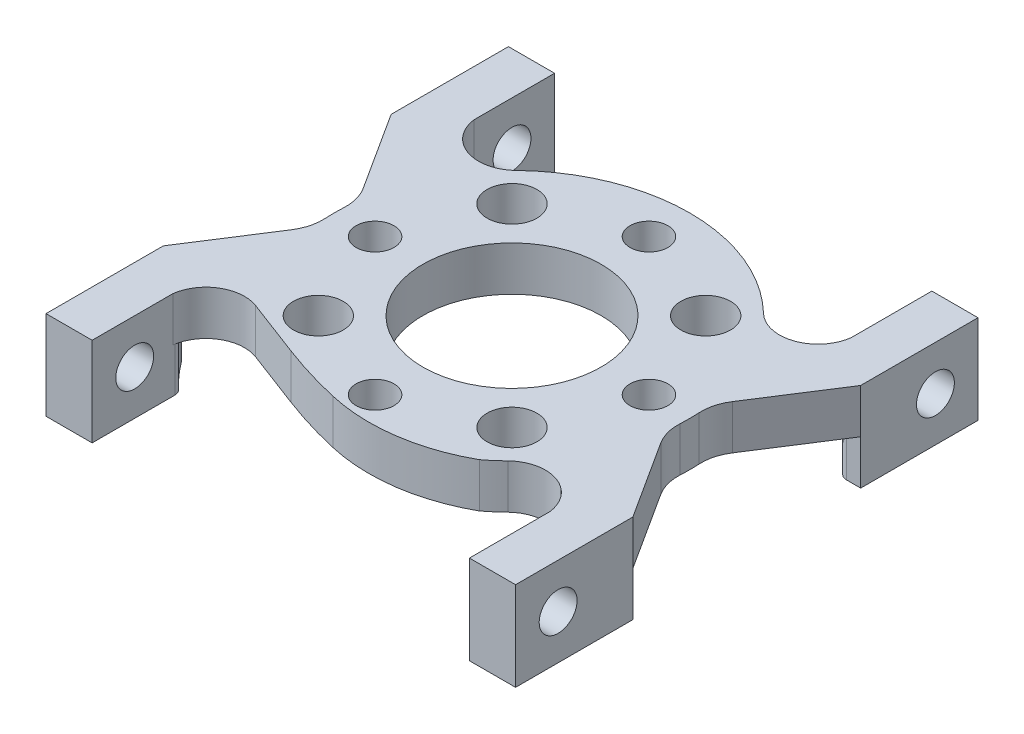
from build123d import *

# Parameters (mm, degrees)
SKETCH1_W                  = 33.528
SKETCH1_H                  = 33.02
BOSS_EXTRUDE1_DEPTH        = 3.175
CUT_EXTRUDE1_DEPTH         = 4.175
SKETCH3_W                  = 3.29438
SKETCH3_H                  = 8.37692
BOSS_EXTRUDE2_DEPTH        = 3.175
CUT_EXTRUDE2_DEPTH         = 7.35
SKETCH5_W                  = 3.29438
SKETCH5_H                  = 8.37692
BOSS_EXTRUDE3_DEPTH        = 3.175
CUT_EXTRUDE3_DEPTH         = 7.35
SKETCH7_W                  = 3.29438
SKETCH7_H                  = 8.37692
BOSS_EXTRUDE4_DEPTH        = 3.175
CUT_EXTRUDE4_DEPTH         = 7.35
SKETCH9_W                  = 3.29438
SKETCH9_H                  = 8.37692
BOSS_EXTRUDE5_DEPTH        = 3.175
CUT_EXTRUDE5_DEPTH         = 3.175
CUT_EXTRUDE6_DEPTH         = 3.175
CUT_EXTRUDE7_DEPTH         = 3.175
CUT_EXTRUDE8_DEPTH         = 3.175
HOLE1_D                    = 12.7254
HOLE1_DEPTH                = 3.175025
M2_5_CLEARANCE_HOLE1_D     = 2.7051
M2_5_CLEARANCE_HOLE1_DEPTH = 3.175025
M3_CLEARANCE_HOLE1_D       = 3.556
M3_CLEARANCE_HOLE1_DEPTH   = 3.175025
M2_5_CLEARANCE_HOLE2_D     = 2.7051
M2_5_CLEARANCE_HOLE2_DEPTH = 3.29438
M2_5_CLEARANCE_HOLE3_D     = 2.7051
M2_5_CLEARANCE_HOLE3_DEPTH = 3.29438
M2_5_CLEARANCE_HOLE4_D     = 2.7051
M2_5_CLEARANCE_HOLE4_DEPTH = 3.29443
FILLET1_R                  = 0.635
FILLET2_R                  = 3.175
CUT_EXTRUDE9_REACH         = 5.175
CUT_EXTRUDE12_REACH        = 7.42
SKETCH30_W                 = 14.449204344
SKETCH30_H                 = 9.791237154


with BuildPart() as part:
    # Sketch1 → Boss-Extrude1 (new body)
    with BuildSketch(Plane.XZ):
        Rectangle(SKETCH1_W, SKETCH1_H)
    extrude(amount=-BOSS_EXTRUDE1_DEPTH)

    # Sketch2 → Cut-Extrude1 (cut, through all)
    with BuildSketch(Plane(origin=(0, 3.175, 0), x_dir=(-1, 0, 0), z_dir=(0, 1, 0))):
        with BuildLine():
            Line((-13.46962, 16.51), (-13.46962, 10.753335779))
            ThreePointArc((-13.46962, 10.753335779), (-11.652039651, 8.508623021), (-8.8307675, 9.127296717))
            ThreePointArc((-8.8307675, 9.127296717), (0, 12.7), (8.8307675, 9.127296717))
            ThreePointArc((8.8307675, 9.127296717), (11.652039651, 8.508623021), (13.46962, 10.753335779))
            Line((13.46962, 10.753335779), (13.46962, 16.51))
            Line((13.46962, 16.51), (-13.46962, 16.51))
        make_face()
    extrude(amount=-CUT_EXTRUDE1_DEPTH, mode=Mode.SUBTRACT)

    # Sketch3 → Boss-Extrude2 (add)
    with BuildSketch(Plane.XZ):
        with Locations((-15.11681, 12.32154)):
            Rectangle(SKETCH3_W, SKETCH3_H)
    extrude(amount=BOSS_EXTRUDE2_DEPTH)

    # Sketch4 → Cut-Extrude2 (cut, through all)
    with BuildSketch(Plane(origin=(0, 3.175, 0), x_dir=(-1, 0, 0), z_dir=(0, 1, 0))):
        with BuildLine():
            Line((-16.764, 8.13308), (-16.764, -8.13308))
            Line((-16.764, -8.13308), (-12.593680427, -1.639882101))
            ThreePointArc((-12.593680427, -1.639882101), (-12.7, 0), (-12.593680427, 1.639882101))
            Line((-12.593680427, 1.639882101), (-16.764, 8.13308))
        make_face()
    extrude(amount=-CUT_EXTRUDE2_DEPTH, mode=Mode.SUBTRACT)

    # Sketch5 → Boss-Extrude3 (add)
    with BuildSketch(Plane.XZ):
        with Locations((15.11681, 12.32154)):
            Rectangle(SKETCH5_W, SKETCH5_H)
    extrude(amount=BOSS_EXTRUDE3_DEPTH)

    # Sketch6 → Cut-Extrude3 (cut, through all)
    with BuildSketch(Plane(origin=(0, 3.175, 0), x_dir=(-1, 0, 0), z_dir=(0, 1, 0))):
        with BuildLine():
            Line((13.46962, -16.51), (13.46962, -10.753335779))
            ThreePointArc((13.46962, -10.753335779), (11.652039651, -8.508623021), (8.8307675, -9.127296717))
            ThreePointArc((8.8307675, -9.127296717), (0, -12.7), (-8.8307675, -9.127296717))
            ThreePointArc((-8.8307675, -9.127296717), (-11.652039651, -8.508623021), (-13.46962, -10.753335779))
            Line((-13.46962, -10.753335779), (-13.46962, -16.51))
            Line((-13.46962, -16.51), (13.46962, -16.51))
        make_face()
    extrude(amount=-CUT_EXTRUDE3_DEPTH, mode=Mode.SUBTRACT)

    # Sketch7 → Boss-Extrude4 (add)
    with BuildSketch(Plane.XZ):
        with Locations((15.11681, -12.32154)):
            Rectangle(SKETCH7_W, SKETCH7_H)
    extrude(amount=BOSS_EXTRUDE4_DEPTH)

    # Sketch8 → Cut-Extrude4 (cut, through all)
    with BuildSketch(Plane(origin=(0, 3.175, 0), x_dir=(-1, 0, 0), z_dir=(0, 1, 0))):
        with BuildLine():
            Line((16.764, -8.13308), (16.764, 8.13308))
            Line((16.764, 8.13308), (12.593680427, 1.639882101))
            ThreePointArc((12.593680427, 1.639882101), (12.7, 0), (12.593680427, -1.639882101))
            Line((12.593680427, -1.639882101), (16.764, -8.13308))
        make_face()
    extrude(amount=-CUT_EXTRUDE4_DEPTH, mode=Mode.SUBTRACT)

    # Sketch9 → Boss-Extrude5 (add)
    with BuildSketch(Plane.XZ):
        with Locations((-15.11681, -12.32154)):
            Rectangle(SKETCH9_W, SKETCH9_H)
    extrude(amount=BOSS_EXTRUDE5_DEPTH)

    # Sketch10 → Cut-Extrude5 (cut)
    with BuildSketch(Plane.XZ.offset(3.175)):
        with BuildLine():
            Line((15.422429016, -8.13308), (13.46962, -8.13308))
            Line((13.46962, -8.13308), (13.46962, -10.329337463))
            ThreePointArc((13.46962, -10.329337463), (14.503938678, -9.282703292), (15.422429016, -8.13308))
        make_face()
    extrude(amount=-CUT_EXTRUDE5_DEPTH, mode=Mode.SUBTRACT)

    # Sketch11 → Cut-Extrude6 (cut)
    with BuildSketch(Plane.XZ.offset(3.175)):
        with BuildLine():
            Line((13.46962, 10.329337463), (13.46962, 8.13308))
            Line((13.46962, 8.13308), (15.422429016, 8.13308))
            ThreePointArc((15.422429016, 8.13308), (14.503938678, 9.282703292), (13.46962, 10.329337463))
        make_face()
    extrude(amount=-CUT_EXTRUDE6_DEPTH, mode=Mode.SUBTRACT)

    # Sketch12 → Cut-Extrude7 (cut)
    with BuildSketch(Plane.XZ.offset(3.175)):
        with BuildLine():
            Line((-15.422429016, 8.13308), (-13.46962, 8.13308))
            Line((-13.46962, 8.13308), (-13.46962, 10.329337463))
            ThreePointArc((-13.46962, 10.329337463), (-14.503938678, 9.282703292), (-15.422429016, 8.13308))
        make_face()
    extrude(amount=-CUT_EXTRUDE7_DEPTH, mode=Mode.SUBTRACT)

    # Sketch13 → Cut-Extrude8 (cut)
    with BuildSketch(Plane.XZ.offset(3.175)):
        with BuildLine():
            Line((-13.46962, -10.329337463), (-13.46962, -8.13308))
            Line((-13.46962, -8.13308), (-15.422429016, -8.13308))
            ThreePointArc((-15.422429016, -8.13308), (-14.503938678, -9.282703292), (-13.46962, -10.329337463))
        make_face()
    extrude(amount=-CUT_EXTRUDE8_DEPTH, mode=Mode.SUBTRACT)

    # Hole1
    with Locations(Plane(origin=(0, 0, 0), x_dir=(-1, 0, 0), z_dir=(0, -1, 0))):
        with Locations((0, 0)):
            Hole(HOLE1_D / 2, depth=HOLE1_DEPTH)

    # M2.5 Clearance Hole1
    with Locations(Plane(origin=(0, 0, 0), x_dir=(-1, 0, 0), z_dir=(0, -1, 0))):
        with Locations((0, -9.779), (9.779, 0), (0, 9.779), (-9.779, 0)):
            Hole(M2_5_CLEARANCE_HOLE1_D / 2, depth=M2_5_CLEARANCE_HOLE1_DEPTH)

    # M3 Clearance Hole1
    with Locations(Plane(origin=(0, 0, 0), x_dir=(-1, 0, 0), z_dir=(0, -1, 0))):
        with Locations((6.914797213, -6.914797213), (6.914797213, 6.914797213), (-6.914797213, 6.914797213), (-6.914797213, -6.914797213)):
            Hole(M3_CLEARANCE_HOLE1_D / 2, depth=M3_CLEARANCE_HOLE1_DEPTH)

    # M2.5 Clearance Hole2
    with Locations(Plane(origin=(16.764, 0, 0), x_dir=(0, 0, -1), z_dir=(1, 0, 0))):
        with Locations((13.470384182, 0)):
            Hole(M2_5_CLEARANCE_HOLE2_D / 2, depth=M2_5_CLEARANCE_HOLE2_DEPTH)

    # M2.5 Clearance Hole3
    with Locations(Plane.ZY.offset(-13.46962)):
        with Locations((13.470384182, 0)):
            Hole(M2_5_CLEARANCE_HOLE3_D / 2, depth=M2_5_CLEARANCE_HOLE3_DEPTH)

    # M2.5 Clearance Hole4
    with Locations(Plane(origin=(-13.46962, 0, 0), x_dir=(0, 0, -1), z_dir=(1, 0, 0))):
        with Locations((-13.470384182, 0), (13.470384182, 0)):
            Hole(M2_5_CLEARANCE_HOLE4_D / 2, depth=M2_5_CLEARANCE_HOLE4_DEPTH)

    # Fillet1
    fillet1_edges = [part.edges().sort_by_distance(p)[0] for p in [
        (-13.46962, -1.5875, -10.329337463),
        (-15.422429016, -1.5875, 8.13308),
        (15.422429016, -1.5875, -8.13308),
        (15.422429016, -1.5875, 8.13308),
        (13.46962, -1.5875, -10.329337463),
        (-13.46962, -1.5875, 10.329337463),
        (-15.422429016, -1.5875, -8.13308),
        (13.46962, -1.5875, 10.329337463),
    ]]
    fillet(fillet1_edges, radius=FILLET1_R)

    # Fillet2
    fillet2_edges = [part.edges().sort_by_distance(p)[0] for p in [
        (-12.593680427, 1.5875, -1.639882101),
        (12.593680427, 1.5875, -1.639882101),
        (-12.593680427, 1.5875, 1.639882101),
        (12.593680427, 1.5875, 1.639882101),
    ]]
    fillet(fillet2_edges, radius=FILLET2_R)

    # Sketch26 → Cut-Extrude9 (cut, up to next)
    with BuildSketch(Plane.XZ, mode=Mode.PRIVATE) as cut_extrude9_sk1:
        with BuildLine():
            Line((-9.767427274, 8.532567661), (-5.711894532, 10.070912798))
            ThreePointArc((-5.711894532, 10.070912798), (-3.581292847, 10.796642581), (-1.406006336, 11.374808519))
            ThreePointArc((-1.406006336, 11.374808519), (3.286728936, 11.571725124), (7.737358426, 10.070912798))
            ThreePointArc((7.737358426, 10.070912798), (-0.72214173, 12.679452327), (-8.8307675, 9.127296717))
            ThreePointArc((-8.8307675, 9.127296717), (-9.268785679, 8.78219321), (-9.767427274, 8.532567661))
        make_face()
    cut_extrude9_tool1 = extrude(cut_extrude9_sk1.sketch, amount=-CUT_EXTRUDE9_REACH, mode=Mode.PRIVATE) & part.part
    add(cut_extrude9_tool1.solids().sort_by_distance((-1.945542, 0, 11.38762))[0], mode=Mode.SUBTRACT)

    # Sketch30 → Cut-Extrude12 (cut, up to next)
    with BuildSketch(Plane(origin=(0, -5.02784088, -3.068243182), x_dir=(-1, 0, 0), z_dir=(0, -0.853608475, -0.520915129)), mode=Mode.PRIVATE) as cut_extrude12_sk1:
        with Locations((0.285206665, 14.086824926)):
            Rectangle(SKETCH30_W, SKETCH30_H)
    cut_extrude12_tool1 = extrude(cut_extrude12_sk1.sketch, amount=CUT_EXTRUDE12_REACH, mode=Mode.PRIVATE) & part.part
    add(cut_extrude12_tool1.solids().sort_by_distance((-0.285207, 2.310199, -15.092876))[0], mode=Mode.SUBTRACT)


solid = part.part
